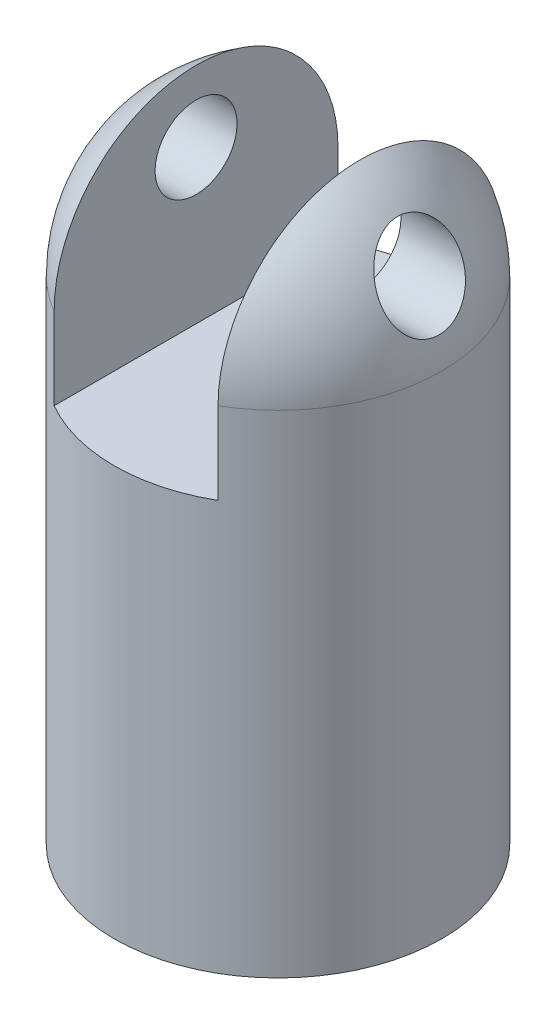
from build123d import *

# Parameters (mm, degrees)
SKETCH2_W          = 25.4
SKETCH2_H          = 38.1
CUT_EXTRUDE1_DEPTH = 101.6
SKETCH3_R          = 6.35
CUT_EXTRUDE2_DEPTH = 101.6
SKETCH4_R          = 6.35
CUT_EXTRUDE3_DEPTH = 25.4


with BuildPart() as part:
    # Sketch1 → Revolve3 (revolve)
    with BuildSketch(Plane.XY):
        with BuildLine():
            Line((0, -50.8), (0, 50.8))
            ThreePointArc((0, 50.8), (17.960512242, 43.360512242), (25.4, 25.4))
            Line((25.4, 25.4), (25.4, -50.8))
            Line((25.4, -50.8), (0, -50.8))
        make_face()
    revolve(axis=Axis((0, -50.8, 0), (0, 1, 0)))

    # Sketch2 → Cut-Extrude1 (cut, symmetric)
    with BuildSketch(Plane.XY):
        with Locations((0, 31.75)):
            Rectangle(SKETCH2_W, SKETCH2_H)
    extrude(amount=CUT_EXTRUDE1_DEPTH, both=True, mode=Mode.SUBTRACT)

    # Sketch3 → Cut-Extrude2 (cut, symmetric)
    with BuildSketch(Plane(origin=(-12.7, 0, 0), x_dir=(0, 0, -1), z_dir=(1, 0, 0))):
        with Locations((0, 36.398522628)):
            Circle(SKETCH3_R)
    extrude(amount=CUT_EXTRUDE2_DEPTH, both=True, mode=Mode.SUBTRACT)

    # Sketch4 → Cut-Extrude3 (cut)
    with BuildSketch(Plane.XZ.offset(50.8)):
        Circle(SKETCH4_R)
    extrude(amount=-CUT_EXTRUDE3_DEPTH, mode=Mode.SUBTRACT)


solid = part.part
